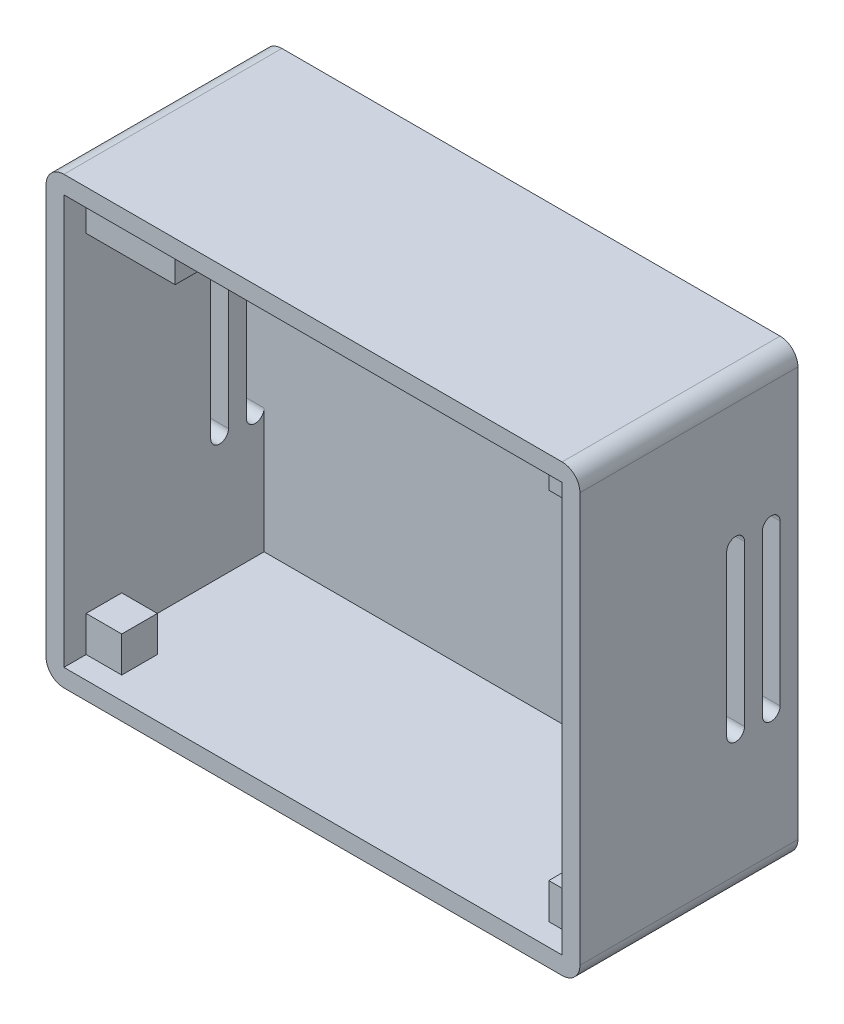
from build123d import *

# Parameters (mm, degrees)
EXTRUDE_8_DEPTH     = 2
EXTRUDE_11_DEPTH    = 20
SKETCH_8_W          = 4
SKETCH_8_H          = 4
EXTRUDE_12_DEPTH    = 4
SKETCH_9_W          = 4
SKETCH_9_H          = 4
EXTRUDE_13_DEPTH    = 4
SKETCH_10_W         = 56
SKETCH_10_H         = 46
EXTRUDE_14_DEPTH    = 2.5
CUT_EXTRUDE_5_DEPTH = 60


with BuildPart() as part:
    # Эскиз1 → Бобышка-Вытянуть8 (new body)
    with BuildSketch(Plane.XY):
        with BuildLine():
            Line((-28, -25), (28, -25))
            ThreePointArc((28, -25), (29.414213562, -24.414213562), (30, -23))
            Line((30, -23), (30, 23))
            ThreePointArc((30, 23), (29.414213562, 24.414213562), (28, 25))
            Line((28, 25), (-28, 25))
            ThreePointArc((-28, 25), (-29.414213562, 24.414213562), (-30, 23))
            Line((-30, 23), (-30, -23))
            ThreePointArc((-30, -23), (-29.414213562, -24.414213562), (-28, -25))
        make_face()
    extrude(amount=EXTRUDE_8_DEPTH)

    # Эскиз6 → Бобышка-Вытянуть11 (add)
    with BuildSketch(Plane.XY.offset(2)):
        with BuildLine():
            Line((-28, 25), (28, 25))
            ThreePointArc((28, 25), (29.414213562, 24.414213562), (30, 23))
            Line((30, 23), (30, -23))
            ThreePointArc((30, -23), (29.414213562, -24.414213562), (28, -25))
            Line((28, -25), (-28, -25))
            ThreePointArc((-28, -25), (-29.414213562, -24.414213562), (-30, -23))
            Line((-30, -23), (-30, 23))
            ThreePointArc((-30, 23), (-29.414213562, 24.414213562), (-28, 25))
        make_face()
        Polygon((-28, -23), (28, -23), (28, 23), (-18, 23), (-18, 18), (-28, 18), align=None, mode=Mode.SUBTRACT)
    extrude(amount=EXTRUDE_11_DEPTH)

    # Эскиз8 → Бобышка-Вытянуть12 (add)
    with BuildSketch(Plane.XZ.offset(-23)):
        with Locations((26, 20)):
            Rectangle(SKETCH_8_W, SKETCH_8_H)
    extrude(amount=EXTRUDE_12_DEPTH)

    # Эскиз9 → Бобышка-Вытянуть13 (add)
    with BuildSketch(Plane(origin=(0, -23, 0), x_dir=(1, 0, 0), z_dir=(0, 1, 0))):
        with Locations((26, -20)):
            Rectangle(SKETCH_9_W, SKETCH_9_H)
        with Locations((-26, -20)):
            Rectangle(SKETCH_9_W, SKETCH_9_H)
    extrude(amount=EXTRUDE_13_DEPTH)

    # Эскиз10 → Бобышка-Вытянуть14 (add)
    with BuildSketch(Plane.XY.offset(22)):
        with BuildLine():
            Line((-28, 25), (28, 25))
            ThreePointArc((28, 25), (29.414213562, 24.414213562), (30, 23))
            Line((30, 23), (30, -23))
            ThreePointArc((30, -23), (29.414213562, -24.414213562), (28, -25))
            Line((28, -25), (-28, -25))
            ThreePointArc((-28, -25), (-29.414213562, -24.414213562), (-30, -23))
            Line((-30, -23), (-30, 23))
            ThreePointArc((-30, 23), (-29.414213562, 24.414213562), (-28, 25))
        make_face()
        Rectangle(SKETCH_10_W, SKETCH_10_H, mode=Mode.SUBTRACT)
    extrude(amount=EXTRUDE_14_DEPTH)

    # Эскиз15 → Вырез-Вытянуть5 (cut)
    with BuildSketch(Plane.ZY.offset(30)):
        with BuildLine():
            Line((8, 9), (8, -9))
            ThreePointArc((8, -9), (7, -10), (6, -9))
            Line((6, -9), (6, 9))
            ThreePointArc((6, 9), (7, 10), (8, 9))
        make_face()
        with BuildLine():
            Line((4, 9), (4, -9))
            ThreePointArc((4, -9), (3, -10), (2, -9))
            Line((2, -9), (2, 9))
            ThreePointArc((2, 9), (3, 10), (4, 9))
        make_face()
    extrude(amount=-CUT_EXTRUDE_5_DEPTH, mode=Mode.SUBTRACT)


solid = part.part
